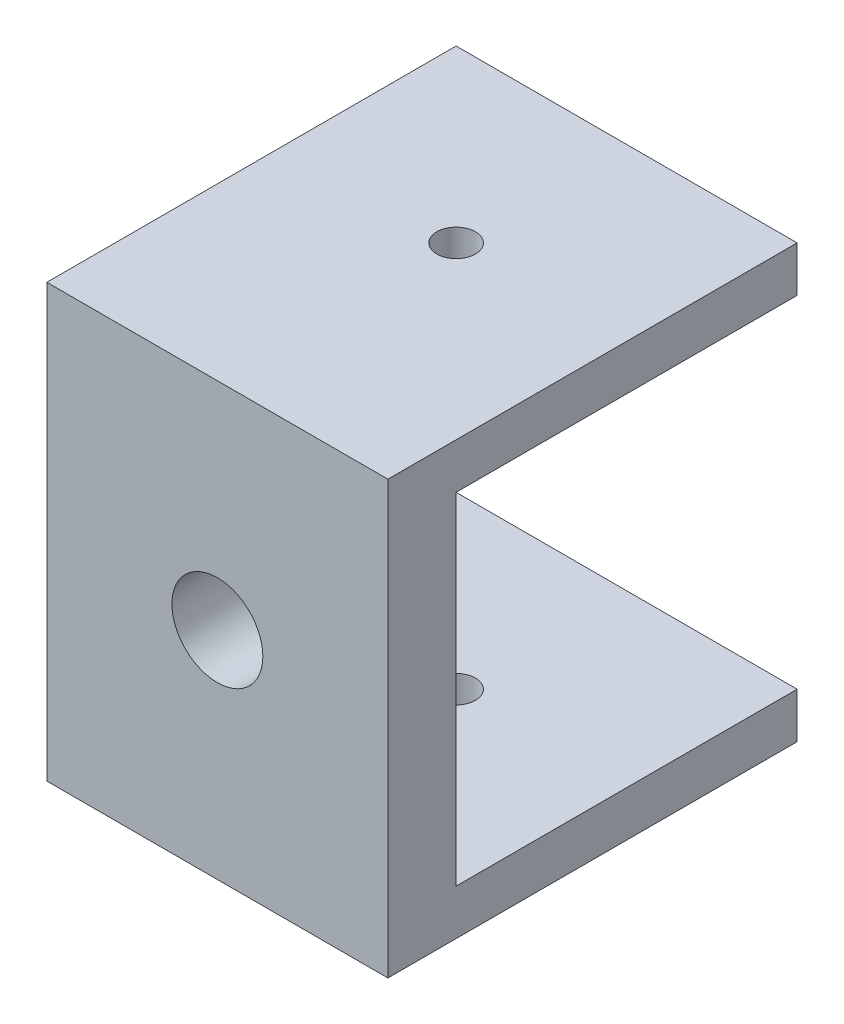
from build123d import *

# Parameters (mm, degrees)
SKETCH2_W           = 6
SKETCH2_H           = 30
BOSS_EXTRUDE1_DEPTH = 30
SKETCH4_R           = 4
CUT_EXTRUDE2_DEPTH  = 30
SKETCH5_R           = 1.7
CUT_EXTRUDE3_DEPTH  = 39


with BuildPart() as part:
    # Sketch2 → Boss-Extrude1 (new body)
    with BuildSketch(Plane(origin=(0, 0, 0), x_dir=(0, 0, -1), z_dir=(1, 0, 0))):
        Rectangle(SKETCH2_W, SKETCH2_H)
        Polygon((-3, 19), (-3, 15), (3, 15), (33, 15), (33, 19), align=None)
        Polygon((3, -15), (-3, -15), (-3, -19), (33, -19), (33, -15), align=None)
    extrude(amount=BOSS_EXTRUDE1_DEPTH)

    # Sketch4 → Cut-Extrude2 (cut)
    with BuildSketch(Plane.XY.offset(3)):
        with Locations((15, 0)):
            Circle(SKETCH4_R)
    extrude(amount=-CUT_EXTRUDE2_DEPTH, mode=Mode.SUBTRACT)

    # Sketch5 → Cut-Extrude3 (cut, through all)
    with BuildSketch(Plane.XZ.offset(19)):
        with Locations((15, -18)):
            Circle(SKETCH5_R)
    extrude(amount=-CUT_EXTRUDE3_DEPTH, mode=Mode.SUBTRACT)


solid = part.part
